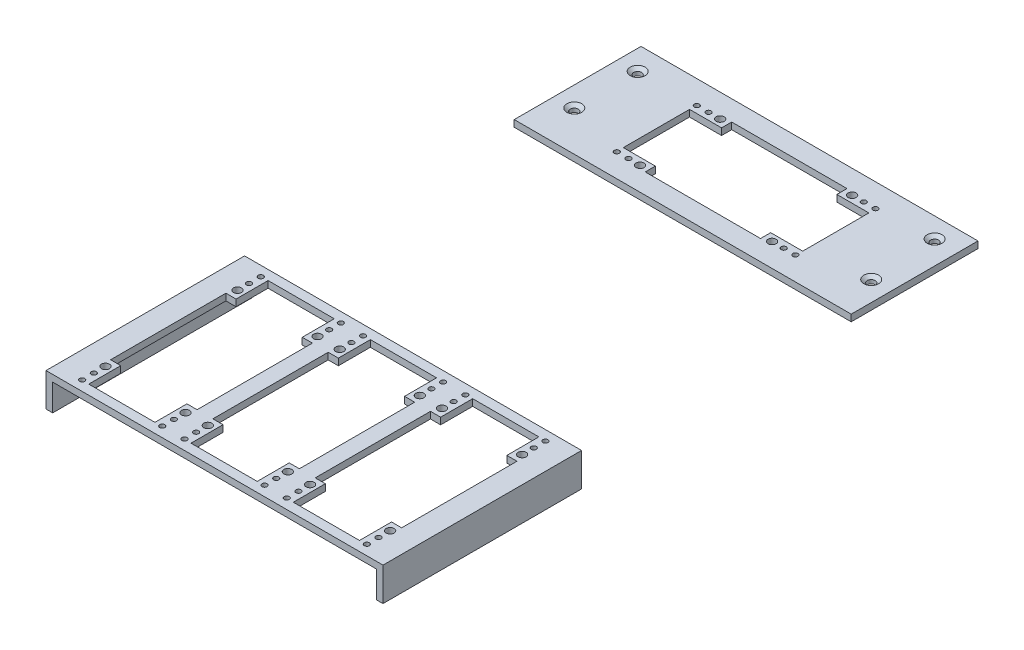
from build123d import *

# Parameters (mm, degrees)
SKETCH1_W                                 = 160.3375
SKETCH1_H                                 = 60.325
SKETCH1_R                                 = 0.254
BOSS_EXTRUDE1_DEPTH                       = 3.175
SKETCH1_H_2                               = 94.488
BOSS_EXTRUDE1_2_DEPTH                     = 3.175
CSK_FOR_6_FLAT_HEAD_MACHINE_SCREW_2_COUNT = 2
CSK_FOR_6_FLAT_HEAD_MACHINE_SCREW_2_PITCH = 30.1625
CSK_FOR_6_FLAT_HEAD_MACHINE_SCREW_3_COUNT = 2
CSK_FOR_6_FLAT_HEAD_MACHINE_SCREW_3_PITCH = 139.709019595
CSK_FOR_6_FLAT_HEAD_MACHINE_SCREW_4_COUNT = 2
CSK_FOR_6_FLAT_HEAD_MACHINE_SCREW_4_PITCH = 144.471222264
SKETCH15_W                                = 3.175
SKETCH15_H                                = 94.488
BOSS_EXTRUDE2_DEPTH                       = 12.7
SKETCH19_R                                = 1.905
SKETCH19_R_2                              = 1.2192
CUT_EXTRUDE1_DEPTH                        = 12.7


with BuildPart() as part:
    # Sketch1 → Boss-Extrude1 (new body)
    with BuildSketch(Plane(origin=(0, 0, 0), x_dir=(1, 0, 0), z_dir=(0, 1, 0))):
        with Locations((80.16875, 30.1625)):
            Rectangle(SKETCH1_W, SKETCH1_H)
        with Locations((9.525, 49.2125)):
            Circle(SKETCH1_R, mode=Mode.SUBTRACT)
        with Locations((9.525, 19.05)):
            Circle(SKETCH1_R, mode=Mode.SUBTRACT)
        with Locations((149.225, 50.8)):
            Circle(SKETCH1_R, mode=Mode.SUBTRACT)
        with Locations((150.8125, 19.05)):
            Circle(SKETCH1_R, mode=Mode.SUBTRACT)
    extrude(amount=BOSS_EXTRUDE1_DEPTH)

    # Sketch12 → CSK for #6 Flat Head Machine Screw (100)2 (revolve, cut)
    with BuildSketch(Plane(origin=(9.525, 3.175, -49.2125), x_dir=(0, 0, 1), z_dir=(1, 0, 0))):
        Polygon((0, 0), (0, 3.175), (1.89865, 3.175), (1.89865, 1.380025208), (3.5433, 0), align=None)
    csk_for_6_flat_head_machine_screw_100 = revolve(axis=Axis((9.525, 9.525, -49.2125), (0, -1, 0)), mode=Mode.SUBTRACT)

    # CSK for _6 Flat Head Machine Screw _ 2: CSK for #6 Flat Head Machine Screw (100)2 ×2
    with Locations(*[(0, 0, i * CSK_FOR_6_FLAT_HEAD_MACHINE_SCREW_2_PITCH) for i in range(1, CSK_FOR_6_FLAT_HEAD_MACHINE_SCREW_2_COUNT)]):
        add(csk_for_6_flat_head_machine_screw_100, mode=Mode.SUBTRACT)

    # CSK for _6 Flat Head Machine Screw _ 3: CSK for #6 Flat Head Machine Screw (100)2 ×2
    with Locations(*[Vector(0.99993544, 0, -0.011362903) * (i * CSK_FOR_6_FLAT_HEAD_MACHINE_SCREW_3_PITCH) for i in range(1, CSK_FOR_6_FLAT_HEAD_MACHINE_SCREW_3_COUNT)]):
        add(csk_for_6_flat_head_machine_screw_100, mode=Mode.SUBTRACT)

    # CSK for _6 Flat Head Machine Screw _ 4: CSK for #6 Flat Head Machine Screw (100)2 ×2
    with Locations(*[Vector(0.977962931, 0, 0.208778603) * (i * CSK_FOR_6_FLAT_HEAD_MACHINE_SCREW_4_PITCH) for i in range(1, CSK_FOR_6_FLAT_HEAD_MACHINE_SCREW_4_COUNT)]):
        add(csk_for_6_flat_head_machine_screw_100, mode=Mode.SUBTRACT)


with BuildPart() as body_2:
    # Sketch1 → Boss-Extrude1 2 (new body)
    with BuildSketch(Plane(origin=(0, 0, 0), x_dir=(1, 0, 0), z_dir=(0, 1, 0))):
        with Locations((72.191460269, -167.561304185)):
            Rectangle(SKETCH1_W, SKETCH1_H_2)
    extrude(amount=BOSS_EXTRUDE1_2_DEPTH)

    # Sketch15 → Boss-Extrude2 (add)
    with BuildSketch(Plane(origin=(0, 0, 0), x_dir=(-1, 0, 0), z_dir=(0, -1, 0))):
        with Locations((-150.772710269, -167.561304185)):
            Rectangle(SKETCH15_W, SKETCH15_H)
        with Locations((6.389789731, -167.561304185)):
            Rectangle(SKETCH15_W, SKETCH15_H)
    extrude(amount=BOSS_EXTRUDE2_DEPTH)


with BuildPart() as cut_extrude1_tool:
    # Sketch19 → Cut-Extrude1 (new body)
    with BuildSketch(Plane(origin=(0, 3.175, 0), x_dir=(1, 0, 0), z_dir=(0, 1, 0))):
        with Locations((42.56877594, -136.166904185)):
            Circle(SKETCH19_R)
        with Locations((42.56877594, -130.629704185)):
            Circle(SKETCH19_R_2)
        with Locations((42.56877594, -125.067104185)):
            Circle(SKETCH19_R_2)
        with Locations((4.46877594, -136.166904185)):
            Circle(SKETCH19_R)
        with Locations((4.46877594, -130.629704185)):
            Circle(SKETCH19_R_2)
        with Locations((4.46877594, -125.067104185)):
            Circle(SKETCH19_R_2)
        with Locations((42.56877594, -210.055504185)):
            Circle(SKETCH19_R_2)
        with Locations((42.56877594, -204.492904185)):
            Circle(SKETCH19_R_2)
        with Locations((42.56877594, -198.955704185)):
            Circle(SKETCH19_R)
        with Locations((4.46877594, -210.055504185)):
            Circle(SKETCH19_R_2)
        with Locations((4.46877594, -204.492904185)):
            Circle(SKETCH19_R_2)
        with Locations((4.46877594, -198.955704185)):
            Circle(SKETCH19_R)
        with Locations((139.914144598, -125.067104185)):
            Circle(SKETCH19_R_2)
        with Locations((139.914144598, -130.629704185)):
            Circle(SKETCH19_R_2)
        with Locations((139.914144598, -136.166904185)):
            Circle(SKETCH19_R)
        with Locations((101.814144598, -136.166904185)):
            Circle(SKETCH19_R)
        with Locations((101.814144598, -130.629704185)):
            Circle(SKETCH19_R_2)
        with Locations((101.814144598, -125.067104185)):
            Circle(SKETCH19_R_2)
        with Locations((91.241460269, -136.166904185)):
            Circle(SKETCH19_R)
        with Locations((91.241460269, -130.629704185)):
            Circle(SKETCH19_R_2)
        with Locations((91.241460269, -125.067104185)):
            Circle(SKETCH19_R_2)
        with Locations((139.914144598, -210.055504185)):
            Circle(SKETCH19_R_2)
        with Locations((139.914144598, -204.492904185)):
            Circle(SKETCH19_R_2)
        with Locations((139.914144598, -198.955704185)):
            Circle(SKETCH19_R)
        with Locations((101.814144598, -210.055504185)):
            Circle(SKETCH19_R_2)
        with Locations((101.814144598, -204.492904185)):
            Circle(SKETCH19_R_2)
        with Locations((101.814144598, -198.955704185)):
            Circle(SKETCH19_R)
        with Locations((91.241460269, -210.055504185)):
            Circle(SKETCH19_R_2)
        with Locations((91.241460269, -204.492904185)):
            Circle(SKETCH19_R_2)
        with Locations((91.241460269, -198.955704185)):
            Circle(SKETCH19_R)
        with Locations((53.141460269, -198.955704185)):
            Circle(SKETCH19_R)
        with Locations((53.141460269, -204.492904185)):
            Circle(SKETCH19_R_2)
        with Locations((53.141460269, -210.055504185)):
            Circle(SKETCH19_R_2)
        with Locations((53.141460269, -136.166904185)):
            Circle(SKETCH19_R)
        with Locations((53.141460269, -130.629704185)):
            Circle(SKETCH19_R_2)
        with Locations((53.141460269, -125.067104185)):
            Circle(SKETCH19_R_2)
        with Locations((37.67455, 49.2125)):
            Circle(SKETCH19_R_2)
        with Locations((43.23715, 49.2125)):
            Circle(SKETCH19_R_2)
        with Locations((48.77435, 49.2125)):
            Circle(SKETCH19_R)
        with Locations((37.67455, 11.1125)):
            Circle(SKETCH19_R_2)
        with Locations((43.23715, 11.1125)):
            Circle(SKETCH19_R_2)
        with Locations((48.77435, 11.1125)):
            Circle(SKETCH19_R)
        with Locations((111.56315, 11.1125)):
            Circle(SKETCH19_R)
        with Locations((117.10035, 11.1125)):
            Circle(SKETCH19_R_2)
        with Locations((122.66295, 11.1125)):
            Circle(SKETCH19_R_2)
        with Locations((122.66295, 49.2125)):
            Circle(SKETCH19_R_2)
        with Locations((117.10035, 49.2125)):
            Circle(SKETCH19_R_2)
        with Locations((111.56315, 49.2125)):
            Circle(SKETCH19_R)
        Polygon((7.77077594, -124.889304185), (39.26677594, -124.889304185), (39.26677594, -140.129304185), (44.09277594, -140.129304185), (44.09277594, -194.993304185), (39.26677594, -194.993304185), (39.26677594, -210.233304185), (7.77077594, -210.233304185), (7.77077594, -194.993304185), (2.94477594, -194.993304185), (2.94477594, -140.129304185), (7.77077594, -140.129304185), align=None)
        Polygon((141.438144598, -140.129304185), (136.612144598, -140.129304185), (136.612144598, -124.889304185), (105.116144598, -124.889304185), (105.116144598, -140.129304185), (100.290144598, -140.129304185), (100.290144598, -194.993304185), (105.116144598, -194.993304185), (105.116144598, -210.233304185), (136.612144598, -210.233304185), (136.612144598, -194.993304185), (141.438144598, -194.993304185), align=None)
        Polygon((56.443460269, -210.233304185), (87.939460269, -210.233304185), (87.939460269, -194.993304185), (92.765460269, -194.993304185), (92.765460269, -140.129304185), (87.939460269, -140.129304185), (87.939460269, -124.889304185), (56.443460269, -124.889304185), (56.443460269, -140.129304185), (51.617460269, -140.129304185), (51.617460269, -194.993304185), (56.443460269, -194.993304185), align=None)
        Polygon((122.84075, 45.9105), (107.60075, 45.9105), (107.60075, 50.7365), (52.73675, 50.7365), (52.73675, 45.9105), (37.49675, 45.9105), (37.49675, 14.4145), (52.73675, 14.4145), (52.73675, 9.5885), (107.60075, 9.5885), (107.60075, 14.4145), (122.84075, 14.4145), align=None)
    extrude(amount=-CUT_EXTRUDE1_DEPTH)


with BuildPart() as part_1:
    add(part.part)

    # Cut-Extrude1: cut by cut_extrude1_tool
    add(cut_extrude1_tool.part, mode=Mode.SUBTRACT)


with BuildPart() as body_2_1:
    add(body_2.part)

    # Cut-Extrude1: cut by cut_extrude1_tool
    add(cut_extrude1_tool.part, mode=Mode.SUBTRACT)


solid = Compound([part_1.part, body_2_1.part])
